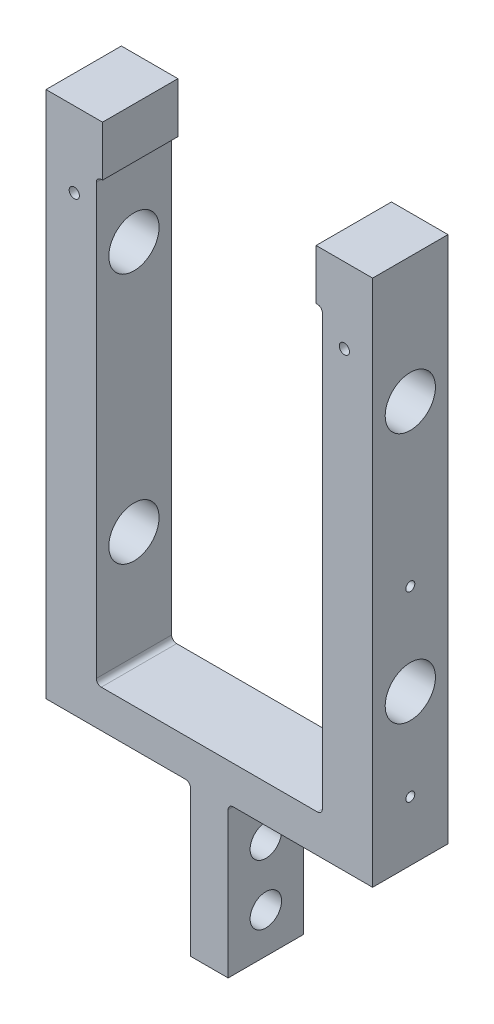
from build123d import *

# Parameters (mm, degrees)
SKETCH1_W                 = 57.15
SKETCH1_H                 = 111.125
BOSS_EXTRUDE1_DEPTH       = 9.525
SKETCH2_R                 = 6.35
CUT_EXTRUDE1_DEPTH        = 83.55
SKETCH4_W                 = 4.7625
SKETCH4_H                 = 19.05
SKETCH4_H_2               = 19.057929795
CUT_EXTRUDE2_DEPTH        = 20.05
F_4_40_TAPPED_HOLE2_D     = 2.2606
F_4_40_TAPPED_HOLE2_DEPTH = 12.7
F_4_40_TAPPED_HOLE2_TIP   = 0.679152758
SKETCH14_W                = 9.525
SKETCH14_H                = 19.05
BOSS_EXTRUDE2_DEPTH       = 19.05
HOLE1_D                   = 7.94512
HOLE1_DEPTH               = 46.0375
HOLE1_TIP                 = 2.386954861
FILLET1_R                 = 1.27
SKETCH17_W                = 53.975
SKETCH17_H                = 12.7
CUT_EXTRUDE3_DEPTH        = 20.05
F_5_40_TAPPED_HOLE1_D     = 2.5781


with BuildPart() as part:
    # Sketch1 → Boss-Extrude1 (new body, symmetric)
    with BuildSketch(Plane.XY):
        Polygon((9.525, 0), (-9.525, 0), (-9.525, 19.05), (-41.275, 19.05), (-41.275, 131.596658994), (-41.275, 152.4), (41.275, 152.4), (41.275, 131.596658994), (41.275, 19.05), (9.525, 19.05), align=None)
        with Locations((0, 84.1375)):
            Rectangle(SKETCH1_W, SKETCH1_H, mode=Mode.SUBTRACT)
    extrude(amount=BOSS_EXTRUDE1_DEPTH, both=True)

    # Sketch2 → Cut-Extrude1 (cut, through all)
    with BuildSketch(Plane.ZY.offset(41.275)):
        with Locations((0, 57.15)):
            Circle(SKETCH2_R)
        with Locations((0, 120.65)):
            Circle(SKETCH2_R)
    extrude(amount=-CUT_EXTRUDE1_DEPTH, mode=Mode.SUBTRACT)

    # Sketch4 → Cut-Extrude2 (cut, through all)
    with BuildSketch(Plane(origin=(0, 0, -9.525), x_dir=(-1, 0, 0), z_dir=(0, 0, -1))):
        with Locations((-7.14375, 9.525)):
            Rectangle(SKETCH4_W, SKETCH4_H)
        with Locations((7.14375, 9.528964897)):
            Rectangle(SKETCH4_W, SKETCH4_H_2)
    extrude(amount=-CUT_EXTRUDE2_DEPTH, mode=Mode.SUBTRACT)

    # #4-40 Tapped Hole2
    with Locations(Plane(origin=(41.275, 0, 0), x_dir=(0, 0, -1), z_dir=(1, 0, 0))):
        with Locations((0, 80.1624), (0, 34.1376)):
            Hole(F_4_40_TAPPED_HOLE2_D / 2, depth=F_4_40_TAPPED_HOLE2_DEPTH)
            with Locations((0, 0, -(F_4_40_TAPPED_HOLE2_DEPTH + F_4_40_TAPPED_HOLE2_TIP / 2))):  # 118° drill point
                Cone(0, F_4_40_TAPPED_HOLE2_D / 2, F_4_40_TAPPED_HOLE2_TIP, mode=Mode.SUBTRACT)

    # Sketch14 → Boss-Extrude2 (add)
    with BuildSketch(Plane.XZ):
        Rectangle(SKETCH14_W, SKETCH14_H)
    extrude(amount=BOSS_EXTRUDE2_DEPTH)

    # Hole1
    with Locations(Plane.ZY.offset(4.7625)):
        with Locations((0, 6.35), (0, -8.89)):
            Hole(HOLE1_D / 2, depth=HOLE1_DEPTH)
            with Locations((0, 0, -(HOLE1_DEPTH + HOLE1_TIP / 2))):  # 118° drill point
                Cone(0, HOLE1_D / 2, HOLE1_TIP, mode=Mode.SUBTRACT)

    # Fillet1
    fillet1_edges = [part.edges().sort_by_distance(p)[0] for p in [
        (28.575, 139.7, 0),
        (-28.575, 139.7, 0),
        (-28.575, 28.575, 0),
        (28.575, 28.575, 0),
        (-4.7625, 19.057929795, 0),
        (4.7625, 19.05, 0),
    ]]
    fillet(fillet1_edges, radius=FILLET1_R)

    # Sketch17 → Cut-Extrude3 (cut, through all)
    with BuildSketch(Plane.XY.offset(9.525)):
        with Locations((0, 146.05)):
            Rectangle(SKETCH17_W, SKETCH17_H)
    extrude(amount=-CUT_EXTRUDE3_DEPTH, mode=Mode.SUBTRACT)

    # #5-40 Tapped Hole1 (through all)
    with Locations(Plane(origin=(0, 0, 9.525), x_dir=(-1, 0, 0), z_dir=(0, 0, 1))):
        with Locations((-34.13125, -133.35), (34.13125, -133.35)):
            Hole(F_5_40_TAPPED_HOLE1_D / 2)


solid = part.part
